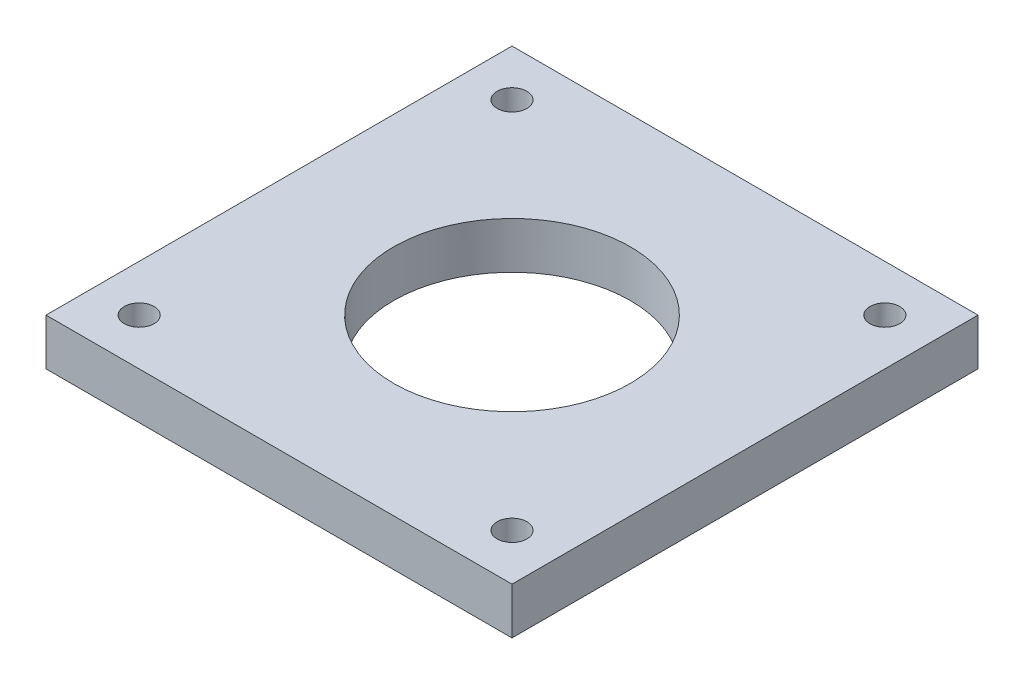
from build123d import *

# Parameters (mm, degrees)
SKETCH1_W                  = 50
SKETCH1_H                  = 50
EXTRUDE1_DEPTH             = 5
LPATTERN1_COUNT            = 2
LPATTERN1_PITCH            = 40
LPATTERN1_COUNT_DIR2       = 2
LPATTERN1_PITCH_DIR2       = 40
F_1_1_DIAMETER_HOLE1_D     = 25.4
F_1_1_DIAMETER_HOLE1_DEPTH = 6
F_1_1_DIAMETER_HOLE1_TIP   = 7.630929862


with BuildPart() as part:
    # Sketch1 → Extrude1 (new body)
    with BuildSketch(Plane(origin=(0, 0, 0), x_dir=(1, 0, 0), z_dir=(0, 1, 0))):
        Rectangle(SKETCH1_W, SKETCH1_H)
    extrude(amount=EXTRUDE1_DEPTH)

    # Sketch2 → M3 Clearance Hole1 (revolve, cut)
    with BuildSketch(Plane(origin=(-20, 5, 20), x_dir=(0, 0, 1), z_dir=(1, 0, 0))):
        Polygon((0, 0), (0, 6.96137699), (1.6, 6), (1.6, 0), align=None)
    m3_clearance_hole1 = revolve(axis=Axis((-20, 11.35, 20), (0, -1, 0)), mode=Mode.SUBTRACT)

    # LPattern1: M3 Clearance Hole1 2 × 2
    with Locations(*[(j * LPATTERN1_PITCH_DIR2, 0, -i * LPATTERN1_PITCH) for i in range(LPATTERN1_COUNT) for j in range(LPATTERN1_COUNT_DIR2) if (i, j) != (0, 0)]):
        add(m3_clearance_hole1, mode=Mode.SUBTRACT)

    # 1 (1) Diameter Hole1
    with Locations(Plane.ZX.offset(5)):
        with Locations((0, 0)):
            Hole(F_1_1_DIAMETER_HOLE1_D / 2, depth=F_1_1_DIAMETER_HOLE1_DEPTH)
            with Locations((0, 0, -(F_1_1_DIAMETER_HOLE1_DEPTH + F_1_1_DIAMETER_HOLE1_TIP / 2))):  # 118° drill point
                Cone(0, F_1_1_DIAMETER_HOLE1_D / 2, F_1_1_DIAMETER_HOLE1_TIP, mode=Mode.SUBTRACT)


solid = part.part
